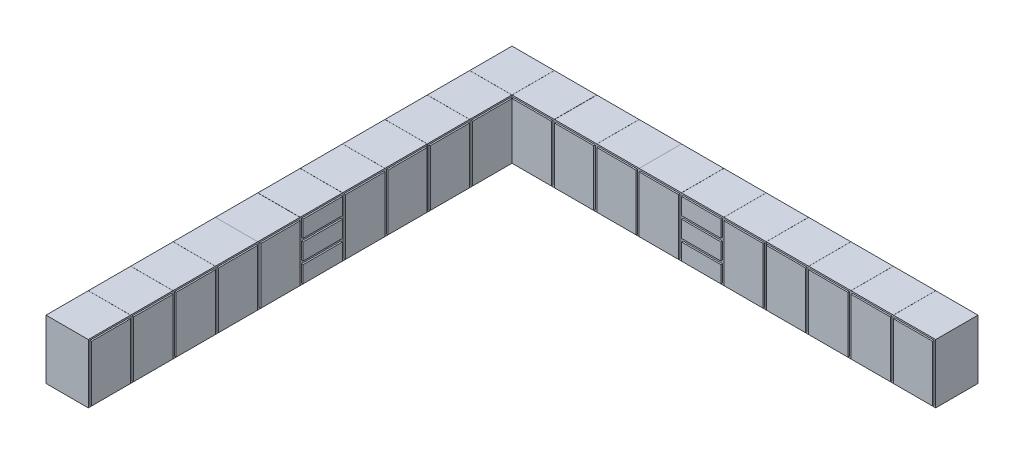
from build123d import *

# Parameters (mm, degrees)
SKETCH5_W           = 550
SKETCH5_H           = 770
BOSS_EXTRUDE8_DEPTH = 550
SKETCH_COPY52_W     = 550
SKETCH_COPY52_H     = 770
COPY52_DEPTH        = 550
SKETCH_COPY52_1_W   = 510
SKETCH_COPY52_1_H   = 730
COPY52_1_DEPTH      = 20
SKETCH_COPY53_W     = 550
SKETCH_COPY53_H     = 770
COPY53_DEPTH        = 550
SKETCH_COPY53_1_W   = 510
SKETCH_COPY53_1_H   = 730
COPY53_1_DEPTH      = 20
SKETCH_COPY54_W     = 550
SKETCH_COPY54_H     = 770
COPY54_DEPTH        = 550
SKETCH_COPY54_1_W   = 510
SKETCH_COPY54_1_H   = 730
COPY54_1_DEPTH      = 20
SKETCH_COPY55_W     = 550
SKETCH_COPY55_H     = 770
COPY55_DEPTH        = 550
SKETCH_COPY55_1_W   = 510
SKETCH_COPY55_1_H   = 730
COPY55_1_DEPTH      = 20
SKETCH_DRAWER2_W    = 550
SKETCH_DRAWER2_H    = 256.6
DRAWER2_DEPTH       = 550
SKETCH_DRAWER2_H_2  = 256.59
DRAWER2_2_DEPTH     = 550
DRAWER2_3_DEPTH     = 550
SKETCH_DRAWER2_1_W  = 510
SKETCH_DRAWER2_1_H  = 216.6
DRAWER2_1_DEPTH     = 20
SKETCH_DRAWER2_2_W  = 510
SKETCH_DRAWER2_2_H  = 216.59
DRAWER2_2_2_DEPTH   = 20
SKETCH_DRAWER2_3_W  = 510
SKETCH_DRAWER2_3_H  = 216.6
DRAWER2_3_2_DEPTH   = 20
SKETCH_COPY56_W     = 550
SKETCH_COPY56_H     = 770
COPY56_DEPTH        = 550
SKETCH_COPY56_1_W   = 510
SKETCH_COPY56_1_H   = 730
COPY56_1_DEPTH      = 20
SKETCH_COPY57_W     = 550
SKETCH_COPY57_H     = 770
COPY57_DEPTH        = 550
SKETCH_COPY57_1_W   = 510
SKETCH_COPY57_1_H   = 730
COPY57_1_DEPTH      = 20
SKETCH_COPY58_W     = 550
SKETCH_COPY58_H     = 770
COPY58_DEPTH        = 550
SKETCH_COPY58_1_W   = 510
SKETCH_COPY58_1_H   = 730
COPY58_1_DEPTH      = 20
SKETCH_COPY59_W     = 550
SKETCH_COPY59_H     = 770
COPY59_DEPTH        = 550
SKETCH_COPY59_1_W   = 510
SKETCH_COPY59_1_H   = 730
COPY59_1_DEPTH      = 20
SKETCH_COPY60_W     = 550
SKETCH_COPY60_H     = 770
COPY60_DEPTH        = 550
SKETCH_COPY60_1_W   = 510
SKETCH_COPY60_1_H   = 730
COPY60_1_DEPTH      = 20
SKETCH_COPY72_W     = 550
SKETCH_COPY72_H     = 770
COPY72_DEPTH        = 550
SKETCH_COPY72_1_W   = 510
SKETCH_COPY72_1_H   = 730
COPY72_1_DEPTH      = 20
SKETCH_COPY73_W     = 550
SKETCH_COPY73_H     = 770
COPY73_DEPTH        = 550
SKETCH_COPY73_1_W   = 510
SKETCH_COPY73_1_H   = 730
COPY73_1_DEPTH      = 20
SKETCH_COPY74_W     = 550
SKETCH_COPY74_H     = 770
COPY74_DEPTH        = 550
SKETCH_COPY74_1_W   = 510
SKETCH_COPY74_1_H   = 730
COPY74_1_DEPTH      = 20
SKETCH_COPY75_W     = 550
SKETCH_COPY75_H     = 770
COPY75_DEPTH        = 550
SKETCH_COPY75_1_W   = 510
SKETCH_COPY75_1_H   = 730
COPY75_1_DEPTH      = 20
SKETCH_COPY76_W     = 550
SKETCH_COPY76_H     = 770
COPY76_DEPTH        = 550
SKETCH_COPY76_1_W   = 510
SKETCH_COPY76_1_H   = 730
COPY76_1_DEPTH      = 20
SKETCH_COPY77_W     = 550
SKETCH_COPY77_H     = 770
COPY77_DEPTH        = 550
SKETCH_COPY77_1_W   = 510
SKETCH_COPY77_1_H   = 730
COPY77_1_DEPTH      = 20
SKETCH_COPY78_W     = 550
SKETCH_COPY78_H     = 770
COPY78_DEPTH        = 550
SKETCH_COPY78_1_W   = 510
SKETCH_COPY78_1_H   = 730
COPY78_1_DEPTH      = 20
SKETCH_COPY79_W     = 550
SKETCH_COPY79_H     = 770
COPY79_DEPTH        = 550
SKETCH_COPY79_1_W   = 510
SKETCH_COPY79_1_H   = 730
COPY79_1_DEPTH      = 20
SKETCH_COPY80_W     = 550
SKETCH_COPY80_H     = 770
COPY80_DEPTH        = 550
SKETCH_COPY80_1_W   = 510
SKETCH_COPY80_1_H   = 730
COPY80_1_DEPTH      = 20
SKETCH_DRAWER1_W    = 550
SKETCH_DRAWER1_H    = 256.6
DRAWER1_DEPTH       = 550
SKETCH_DRAWER1_H_2  = 256.5
DRAWER1_2_DEPTH     = 550
DRAWER1_3_DEPTH     = 550
SKETCH_DRAWER1_1_W  = 510
SKETCH_DRAWER1_1_H  = 216.6
DRAWER1_1_DEPTH     = 20
SKETCH_DRAWER1_2_W  = 510
SKETCH_DRAWER1_2_H  = 216.5
DRAWER1_2_2_DEPTH   = 20
SKETCH_DRAWER1_3_W  = 510
SKETCH_DRAWER1_3_H  = 216.5
DRAWER1_3_2_DEPTH   = 20


with BuildPart() as part:
    # Sketch5 → Boss-Extrude8 (new body)
    with BuildSketch(Plane.XY):
        with Locations((-54.294928207, 117.298806907)):
            Rectangle(SKETCH5_W, SKETCH5_H)
    extrude(amount=BOSS_EXTRUDE8_DEPTH)


with BuildPart() as body_2:
    # Sketch-Copy52 → Copy52 (new body)
    with BuildSketch(Plane.XY):
        with Locations((496.705071793, 117.298806907)):
            Rectangle(SKETCH_COPY52_W, SKETCH_COPY52_H)
    extrude(amount=COPY52_DEPTH)

    # Sketch-Copy52-1 → Copy52-1 (add)
    with BuildSketch(Plane.XY.offset(550)):
        with Locations((496.705071793, 117.298806907)):
            Rectangle(SKETCH_COPY52_1_W, SKETCH_COPY52_1_H)
    extrude(amount=COPY52_1_DEPTH)


with BuildPart() as body_3:
    # Sketch-Copy53 → Copy53 (new body)
    with BuildSketch(Plane.XY):
        with Locations((1048.705071793, 117.298806907)):
            Rectangle(SKETCH_COPY53_W, SKETCH_COPY53_H)
    extrude(amount=COPY53_DEPTH)

    # Sketch-Copy53-1 → Copy53-1 (add)
    with BuildSketch(Plane.XY.offset(550)):
        with Locations((1048.705071793, 117.298806907)):
            Rectangle(SKETCH_COPY53_1_W, SKETCH_COPY53_1_H)
    extrude(amount=COPY53_1_DEPTH)


with BuildPart() as body_4:
    # Sketch-Copy54 → Copy54 (new body)
    with BuildSketch(Plane.XY):
        with Locations((1599.705071793, 117.298806907)):
            Rectangle(SKETCH_COPY54_W, SKETCH_COPY54_H)
    extrude(amount=COPY54_DEPTH)

    # Sketch-Copy54-1 → Copy54-1 (add)
    with BuildSketch(Plane.XY.offset(550)):
        with Locations((1599.705071793, 117.298806907)):
            Rectangle(SKETCH_COPY54_1_W, SKETCH_COPY54_1_H)
    extrude(amount=COPY54_1_DEPTH)


with BuildPart() as body_5:
    # Sketch-Copy55 → Copy55 (new body)
    with BuildSketch(Plane.XY):
        with Locations((2149.705071793, 117.298806907)):
            Rectangle(SKETCH_COPY55_W, SKETCH_COPY55_H)
    extrude(amount=COPY55_DEPTH)

    # Sketch-Copy55-1 → Copy55-1 (add)
    with BuildSketch(Plane.XY.offset(550)):
        with Locations((2149.705071793, 117.298806907)):
            Rectangle(SKETCH_COPY55_1_W, SKETCH_COPY55_1_H)
    extrude(amount=COPY55_1_DEPTH)


with BuildPart() as body_6:
    # Sketch-Drawer2 → Drawer2 (new body)
    with BuildSketch(Plane.XY):
        with Locations((2700.705071793, -139.401193093)):
            Rectangle(SKETCH_DRAWER2_W, SKETCH_DRAWER2_H)
    extrude(amount=DRAWER2_DEPTH)

    # Sketch-Drawer2-3 → Drawer2-3 2 (add)
    with BuildSketch(Plane.XY.offset(550)):
        with Locations((2700.705071793, -139.401193093)):
            Rectangle(SKETCH_DRAWER2_3_W, SKETCH_DRAWER2_3_H)
    extrude(amount=DRAWER2_3_2_DEPTH)


with BuildPart() as body_7:
    # Sketch-Drawer2 → Drawer2 2 (new body)
    with BuildSketch(Plane.XY):
        with Locations((2700.705071793, 117.203806907)):
            Rectangle(SKETCH_DRAWER2_W, SKETCH_DRAWER2_H_2)
    extrude(amount=DRAWER2_2_DEPTH)

    # Sketch-Drawer2-2 → Drawer2-2 2 (add)
    with BuildSketch(Plane.XY.offset(550)):
        with Locations((2700.705071793, 117.203806907)):
            Rectangle(SKETCH_DRAWER2_2_W, SKETCH_DRAWER2_2_H)
    extrude(amount=DRAWER2_2_2_DEPTH)


with BuildPart() as body_8:
    # Sketch-Drawer2 → Drawer2 3 (new body)
    with BuildSketch(Plane.XY):
        with Locations((2700.705071793, 373.808806907)):
            Rectangle(SKETCH_DRAWER2_W, SKETCH_DRAWER2_H)
    extrude(amount=DRAWER2_3_DEPTH)

    # Sketch-Drawer2-1 → Drawer2-1 (add)
    with BuildSketch(Plane.XY.offset(550)):
        with Locations((2700.705071793, 373.808806907)):
            Rectangle(SKETCH_DRAWER2_1_W, SKETCH_DRAWER2_1_H)
    extrude(amount=DRAWER2_1_DEPTH)


with BuildPart() as body_9:
    # Sketch-Copy56 → Copy56 (new body)
    with BuildSketch(Plane.XY):
        with Locations((3251.705071793, 117.298806907)):
            Rectangle(SKETCH_COPY56_W, SKETCH_COPY56_H)
    extrude(amount=COPY56_DEPTH)

    # Sketch-Copy56-1 → Copy56-1 (add)
    with BuildSketch(Plane.XY.offset(550)):
        with Locations((3251.705071793, 117.298806907)):
            Rectangle(SKETCH_COPY56_1_W, SKETCH_COPY56_1_H)
    extrude(amount=COPY56_1_DEPTH)


with BuildPart() as body_10:
    # Sketch-Copy57 → Copy57 (new body)
    with BuildSketch(Plane.XY):
        with Locations((3802.705071793, 117.298806907)):
            Rectangle(SKETCH_COPY57_W, SKETCH_COPY57_H)
    extrude(amount=COPY57_DEPTH)

    # Sketch-Copy57-1 → Copy57-1 (add)
    with BuildSketch(Plane.XY.offset(550)):
        with Locations((3802.705071793, 117.298806907)):
            Rectangle(SKETCH_COPY57_1_W, SKETCH_COPY57_1_H)
    extrude(amount=COPY57_1_DEPTH)


with BuildPart() as body_11:
    # Sketch-Copy58 → Copy58 (new body)
    with BuildSketch(Plane.XY):
        with Locations((4353.705071793, 117.298806907)):
            Rectangle(SKETCH_COPY58_W, SKETCH_COPY58_H)
    extrude(amount=COPY58_DEPTH)

    # Sketch-Copy58-1 → Copy58-1 (add)
    with BuildSketch(Plane.XY.offset(550)):
        with Locations((4353.705071793, 117.298806907)):
            Rectangle(SKETCH_COPY58_1_W, SKETCH_COPY58_1_H)
    extrude(amount=COPY58_1_DEPTH)


with BuildPart() as body_12:
    # Sketch-Copy59 → Copy59 (new body)
    with BuildSketch(Plane.XY):
        with Locations((4904.705071793, 117.298806907)):
            Rectangle(SKETCH_COPY59_W, SKETCH_COPY59_H)
    extrude(amount=COPY59_DEPTH)

    # Sketch-Copy59-1 → Copy59-1 (add)
    with BuildSketch(Plane.XY.offset(550)):
        with Locations((4904.705071793, 117.298806907)):
            Rectangle(SKETCH_COPY59_1_W, SKETCH_COPY59_1_H)
    extrude(amount=COPY59_1_DEPTH)


with BuildPart() as body_13:
    # Sketch-Copy60 → Copy60 (new body)
    with BuildSketch(Plane.XY):
        with Locations((5455.705071793, 117.298806907)):
            Rectangle(SKETCH_COPY60_W, SKETCH_COPY60_H)
    extrude(amount=COPY60_DEPTH)

    # Sketch-Copy60-1 → Copy60-1 (add)
    with BuildSketch(Plane.XY.offset(550)):
        with Locations((5455.705071793, 117.298806907)):
            Rectangle(SKETCH_COPY60_1_W, SKETCH_COPY60_1_H)
    extrude(amount=COPY60_1_DEPTH)


with BuildPart() as body_14:
    # Sketch-Copy72 → Copy72 (new body)
    with BuildSketch(Plane(origin=(-329.294928207, 0, 0), x_dir=(0, 0, -1), z_dir=(1, 0, 0))):
        with Locations((-826, 117.298806907)):
            Rectangle(SKETCH_COPY72_W, SKETCH_COPY72_H)
    extrude(amount=COPY72_DEPTH)

    # Sketch-Copy72-1 → Copy72-1 (add)
    with BuildSketch(Plane(origin=(220.705071793, 0, 0), x_dir=(0, 0, -1), z_dir=(1, 0, 0))):
        with Locations((-826, 117.298806907)):
            Rectangle(SKETCH_COPY72_1_W, SKETCH_COPY72_1_H)
    extrude(amount=COPY72_1_DEPTH)


with BuildPart() as body_15:
    # Sketch-Copy73 → Copy73 (new body)
    with BuildSketch(Plane(origin=(-329.294928207, 0, 0), x_dir=(0, 0, -1), z_dir=(1, 0, 0))):
        with Locations((-1377, 117.298806907)):
            Rectangle(SKETCH_COPY73_W, SKETCH_COPY73_H)
    extrude(amount=COPY73_DEPTH)

    # Sketch-Copy73-1 → Copy73-1 (add)
    with BuildSketch(Plane(origin=(220.705071793, 0, 0), x_dir=(0, 0, -1), z_dir=(1, 0, 0))):
        with Locations((-1377, 117.298806907)):
            Rectangle(SKETCH_COPY73_1_W, SKETCH_COPY73_1_H)
    extrude(amount=COPY73_1_DEPTH)


with BuildPart() as body_16:
    # Sketch-Copy74 → Copy74 (new body)
    with BuildSketch(Plane(origin=(-329.294928207, 0, 0), x_dir=(0, 0, -1), z_dir=(1, 0, 0))):
        with Locations((-1928, 117.298806907)):
            Rectangle(SKETCH_COPY74_W, SKETCH_COPY74_H)
    extrude(amount=COPY74_DEPTH)

    # Sketch-Copy74-1 → Copy74-1 (add)
    with BuildSketch(Plane(origin=(220.705071793, 0, 0), x_dir=(0, 0, -1), z_dir=(1, 0, 0))):
        with Locations((-1928, 117.298806907)):
            Rectangle(SKETCH_COPY74_1_W, SKETCH_COPY74_1_H)
    extrude(amount=COPY74_1_DEPTH)


with BuildPart() as body_17:
    # Sketch-Copy75 → Copy75 (new body)
    with BuildSketch(Plane(origin=(-329.294928207, 0, 0), x_dir=(0, 0, -1), z_dir=(1, 0, 0))):
        with Locations((-2479, 117.298806907)):
            Rectangle(SKETCH_COPY75_W, SKETCH_COPY75_H)
    extrude(amount=COPY75_DEPTH)

    # Sketch-Copy75-1 → Copy75-1 (add)
    with BuildSketch(Plane(origin=(220.705071793, 0, 0), x_dir=(0, 0, -1), z_dir=(1, 0, 0))):
        with Locations((-2479, 117.298806907)):
            Rectangle(SKETCH_COPY75_1_W, SKETCH_COPY75_1_H)
    extrude(amount=COPY75_1_DEPTH)


with BuildPart() as body_18:
    # Sketch-Copy76 → Copy76 (new body)
    with BuildSketch(Plane(origin=(-329.294928207, 0, 0), x_dir=(0, 0, -1), z_dir=(1, 0, 0))):
        with Locations((-3582, 117.298806907)):
            Rectangle(SKETCH_COPY76_W, SKETCH_COPY76_H)
    extrude(amount=COPY76_DEPTH)

    # Sketch-Copy76-1 → Copy76-1 (add)
    with BuildSketch(Plane(origin=(220.705071793, 0, 0), x_dir=(0, 0, -1), z_dir=(1, 0, 0))):
        with Locations((-3582, 117.298806907)):
            Rectangle(SKETCH_COPY76_1_W, SKETCH_COPY76_1_H)
    extrude(amount=COPY76_1_DEPTH)


with BuildPart() as body_19:
    # Sketch-Copy77 → Copy77 (new body)
    with BuildSketch(Plane(origin=(-329.294928207, 0, 0), x_dir=(0, 0, -1), z_dir=(1, 0, 0))):
        with Locations((-4132, 117.298806907)):
            Rectangle(SKETCH_COPY77_W, SKETCH_COPY77_H)
    extrude(amount=COPY77_DEPTH)

    # Sketch-Copy77-1 → Copy77-1 (add)
    with BuildSketch(Plane(origin=(220.705071793, 0, 0), x_dir=(0, 0, -1), z_dir=(1, 0, 0))):
        with Locations((-4132, 117.298806907)):
            Rectangle(SKETCH_COPY77_1_W, SKETCH_COPY77_1_H)
    extrude(amount=COPY77_1_DEPTH)


with BuildPart() as body_20:
    # Sketch-Copy78 → Copy78 (new body)
    with BuildSketch(Plane(origin=(-329.294928207, 0, 0), x_dir=(0, 0, -1), z_dir=(1, 0, 0))):
        with Locations((-4683, 117.298806907)):
            Rectangle(SKETCH_COPY78_W, SKETCH_COPY78_H)
    extrude(amount=COPY78_DEPTH)

    # Sketch-Copy78-1 → Copy78-1 (add)
    with BuildSketch(Plane(origin=(220.705071793, 0, 0), x_dir=(0, 0, -1), z_dir=(1, 0, 0))):
        with Locations((-4683, 117.298806907)):
            Rectangle(SKETCH_COPY78_1_W, SKETCH_COPY78_1_H)
    extrude(amount=COPY78_1_DEPTH)


with BuildPart() as body_21:
    # Sketch-Copy79 → Copy79 (new body)
    with BuildSketch(Plane(origin=(-329.294928207, 0, 0), x_dir=(0, 0, -1), z_dir=(1, 0, 0))):
        with Locations((-5234, 117.298806907)):
            Rectangle(SKETCH_COPY79_W, SKETCH_COPY79_H)
    extrude(amount=COPY79_DEPTH)

    # Sketch-Copy79-1 → Copy79-1 (add)
    with BuildSketch(Plane(origin=(220.705071793, 0, 0), x_dir=(0, 0, -1), z_dir=(1, 0, 0))):
        with Locations((-5234, 117.298806907)):
            Rectangle(SKETCH_COPY79_1_W, SKETCH_COPY79_1_H)
    extrude(amount=COPY79_1_DEPTH)


with BuildPart() as body_22:
    # Sketch-Copy80 → Copy80 (new body)
    with BuildSketch(Plane(origin=(-329.294928207, 0, 0), x_dir=(0, 0, -1), z_dir=(1, 0, 0))):
        with Locations((-5785, 117.298806907)):
            Rectangle(SKETCH_COPY80_W, SKETCH_COPY80_H)
    extrude(amount=COPY80_DEPTH)

    # Sketch-Copy80-1 → Copy80-1 (add)
    with BuildSketch(Plane(origin=(220.705071793, 0, 0), x_dir=(0, 0, -1), z_dir=(1, 0, 0))):
        with Locations((-5785, 117.298806907)):
            Rectangle(SKETCH_COPY80_1_W, SKETCH_COPY80_1_H)
    extrude(amount=COPY80_1_DEPTH)


with BuildPart() as body_23:
    # Sketch-Drawer1 → Drawer1 (new body)
    with BuildSketch(Plane(origin=(-329.294928207, 0, 0), x_dir=(0, 0, -1), z_dir=(1, 0, 0))):
        with Locations((-3030, 373.798806907)):
            Rectangle(SKETCH_DRAWER1_W, SKETCH_DRAWER1_H)
    extrude(amount=DRAWER1_DEPTH)

    # Sketch-Drawer1-1 → Drawer1-1 (add)
    with BuildSketch(Plane(origin=(220.705071793, 0, 0), x_dir=(0, 0, -1), z_dir=(1, 0, 0))):
        with Locations((-3030, 373.798806907)):
            Rectangle(SKETCH_DRAWER1_1_W, SKETCH_DRAWER1_1_H)
    extrude(amount=DRAWER1_1_DEPTH)


with BuildPart() as body_24:
    # Sketch-Drawer1 → Drawer1 2 (new body)
    with BuildSketch(Plane(origin=(-329.294928207, 0, 0), x_dir=(0, 0, -1), z_dir=(1, 0, 0))):
        with Locations((-3030, 117.148806907)):
            Rectangle(SKETCH_DRAWER1_W, SKETCH_DRAWER1_H_2)
    extrude(amount=DRAWER1_2_DEPTH)

    # Sketch-Drawer1-2 → Drawer1-2 2 (add)
    with BuildSketch(Plane(origin=(220.705071793, 0, 0), x_dir=(0, 0, -1), z_dir=(1, 0, 0))):
        with Locations((-3030, 117.148806907)):
            Rectangle(SKETCH_DRAWER1_2_W, SKETCH_DRAWER1_2_H)
    extrude(amount=DRAWER1_2_2_DEPTH)


with BuildPart() as body_25:
    # Sketch-Drawer1 → Drawer1 3 (new body)
    with BuildSketch(Plane(origin=(-329.294928207, 0, 0), x_dir=(0, 0, -1), z_dir=(1, 0, 0))):
        with Locations((-3030, -139.451193093)):
            Rectangle(SKETCH_DRAWER1_W, SKETCH_DRAWER1_H_2)
    extrude(amount=DRAWER1_3_DEPTH)

    # Sketch-Drawer1-3 → Drawer1-3 2 (add)
    with BuildSketch(Plane(origin=(220.705071793, 0, 0), x_dir=(0, 0, -1), z_dir=(1, 0, 0))):
        with Locations((-3030, -139.451193093)):
            Rectangle(SKETCH_DRAWER1_3_W, SKETCH_DRAWER1_3_H)
    extrude(amount=DRAWER1_3_2_DEPTH)


solid = Compound([part.part, body_2.part, body_3.part, body_4.part, body_5.part, body_6.part, body_7.part, body_8.part, body_9.part, body_10.part, body_11.part, body_12.part, body_13.part, body_14.part, body_15.part, body_16.part, body_17.part, body_18.part, body_19.part, body_20.part, body_21.part, body_22.part, body_23.part, body_24.part, body_25.part])
